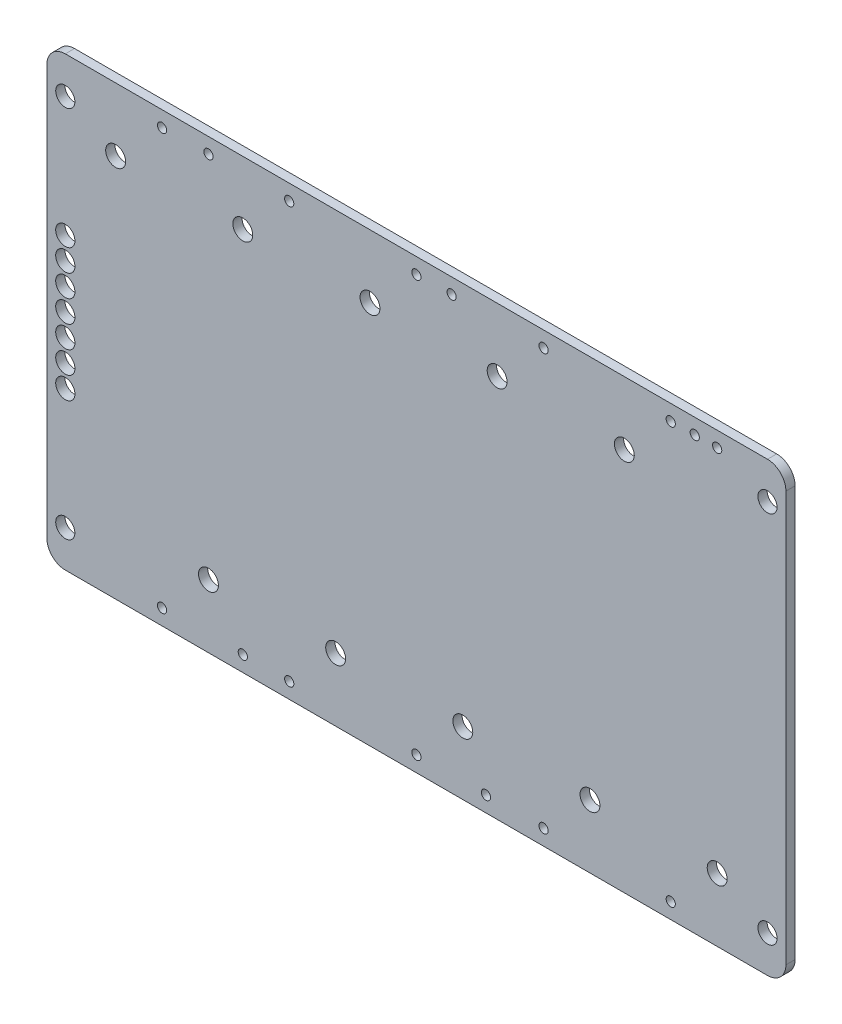
from build123d import *

# Parameters (mm, degrees)
SKETCH1_W           = 127.381
SKETCH1_H           = 77.0636
SKETCH1_R           = 1.651
SKETCH1_R_2         = 0.79375
SKETCH1_R_3         = 1.7145
SKETCH1_R_4         = 1.659299133
BOSS_EXTRUDE1_DEPTH = 1.5875
FILLET1_R           = 3.175


with BuildPart() as part:
    # Sketch1 → Boss-Extrude1 (new body)
    with BuildSketch(Plane.XY):
        with Locations((54.1655, 38.5318)):
            Rectangle(SKETCH1_W, SKETCH1_H)
        with Locations((-6.35, 6.35)):
            Circle(SKETCH1_R, mode=Mode.SUBTRACT)
        with Locations((10.3251, 2.6924)):
            Circle(SKETCH1_R_2, mode=Mode.SUBTRACT)
        with Locations((24.2443, 2.6924)):
            Circle(SKETCH1_R_2, mode=Mode.SUBTRACT)
        with Locations((18.3261, 10.9093)):
            Circle(SKETCH1_R_3, mode=Mode.SUBTRACT)
        with Locations((32.2453, 2.6924)):
            Circle(SKETCH1_R_2, mode=Mode.SUBTRACT)
        with Locations((54.1655, 2.6924)):
            Circle(SKETCH1_R_2, mode=Mode.SUBTRACT)
        with Locations((40.2463, 10.9093)):
            Circle(SKETCH1_R_3, mode=Mode.SUBTRACT)
        with Locations((-6.35, 27.1018)):
            Circle(SKETCH1_R_4, mode=Mode.SUBTRACT)
        with Locations((-6.35, 30.9118)):
            Circle(SKETCH1_R_4, mode=Mode.SUBTRACT)
        with Locations((-6.35, 34.7218)):
            Circle(SKETCH1_R_4, mode=Mode.SUBTRACT)
        with Locations((66.1543, 2.6924)):
            Circle(SKETCH1_R_2, mode=Mode.SUBTRACT)
        with Locations((76.0857, 2.6924)):
            Circle(SKETCH1_R_2, mode=Mode.SUBTRACT)
        with Locations((62.1665, 10.9093)):
            Circle(SKETCH1_R_3, mode=Mode.SUBTRACT)
        with Locations((84.0867, 10.9093)):
            Circle(SKETCH1_R_3, mode=Mode.SUBTRACT)
        with Locations((98.0059, 2.6924)):
            Circle(SKETCH1_R_2, mode=Mode.SUBTRACT)
        with Locations((114.681, 6.35)):
            Circle(SKETCH1_R, mode=Mode.SUBTRACT)
        with Locations((106.0069, 10.9093)):
            Circle(SKETCH1_R_3, mode=Mode.SUBTRACT)
        with Locations((-6.35, 38.5318)):
            Circle(SKETCH1_R_4, mode=Mode.SUBTRACT)
        with Locations((-6.35, 42.3418)):
            Circle(SKETCH1_R_4, mode=Mode.SUBTRACT)
        with Locations((-6.35, 46.1518)):
            Circle(SKETCH1_R_4, mode=Mode.SUBTRACT)
        with Locations((-6.35, 49.9618)):
            Circle(SKETCH1_R_4, mode=Mode.SUBTRACT)
        with Locations((2.3241, 66.1543)):
            Circle(SKETCH1_R_3, mode=Mode.SUBTRACT)
        with Locations((24.2443, 66.1543)):
            Circle(SKETCH1_R_3, mode=Mode.SUBTRACT)
        with Locations((-6.35, 70.7136)):
            Circle(SKETCH1_R, mode=Mode.SUBTRACT)
        with Locations((10.3251, 74.3712)):
            Circle(SKETCH1_R_2, mode=Mode.SUBTRACT)
        with Locations((18.3261, 74.4347)):
            Circle(SKETCH1_R_2, mode=Mode.SUBTRACT)
        with Locations((46.1645, 66.1543)):
            Circle(SKETCH1_R_3, mode=Mode.SUBTRACT)
        with Locations((32.2453, 74.3712)):
            Circle(SKETCH1_R_2, mode=Mode.SUBTRACT)
        with Locations((54.1655, 74.3712)):
            Circle(SKETCH1_R_2, mode=Mode.SUBTRACT)
        with Locations((68.0847, 66.1543)):
            Circle(SKETCH1_R_3, mode=Mode.SUBTRACT)
        with Locations((90.0049, 66.1543)):
            Circle(SKETCH1_R_3, mode=Mode.SUBTRACT)
        with Locations((60.2361, 74.4347)):
            Circle(SKETCH1_R_2, mode=Mode.SUBTRACT)
        with Locations((76.0857, 74.3712)):
            Circle(SKETCH1_R_2, mode=Mode.SUBTRACT)
        with Locations((98.0059, 74.3712)):
            Circle(SKETCH1_R_2, mode=Mode.SUBTRACT)
        with Locations((102.1461, 74.4347)):
            Circle(SKETCH1_R_2, mode=Mode.SUBTRACT)
        with Locations((106.0069, 74.4347)):
            Circle(SKETCH1_R_2, mode=Mode.SUBTRACT)
        with Locations((114.681, 70.7136)):
            Circle(SKETCH1_R, mode=Mode.SUBTRACT)
    extrude(amount=BOSS_EXTRUDE1_DEPTH)

    # Fillet1
    fillet1_edges = [part.edges().sort_by_distance(p)[0] for p in [
        (-9.525, 77.0636, 0.79375),
        (117.856, 77.0636, 0.79375),
        (117.856, 0, 0.79375),
        (-9.525, 0, 0.79375),
    ]]
    fillet(fillet1_edges, radius=FILLET1_R)


solid = part.part
